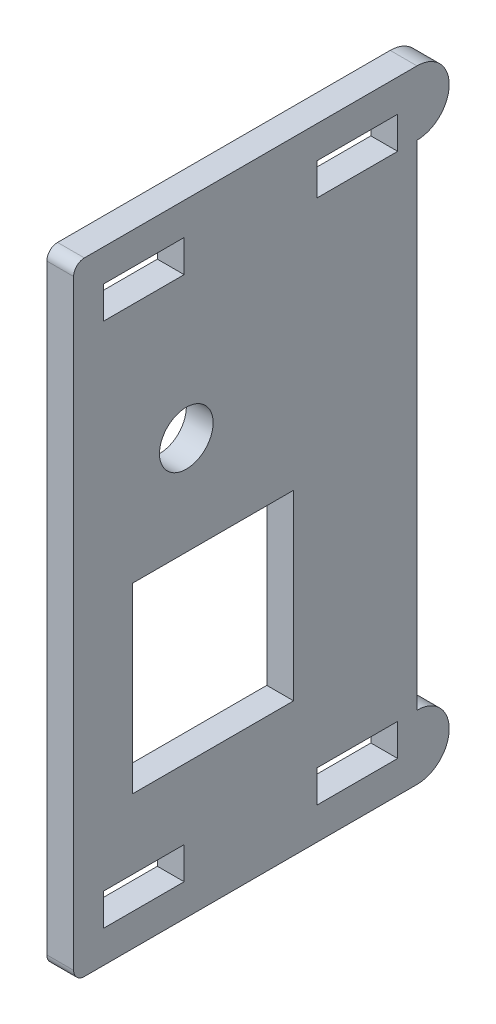
from build123d import *

# Parameters (mm, degrees)
SKETCH_2_W          = 35
SKETCH_2_H          = 58
EXTRUDE_1_DEPTH     = 2.5
SKETCH_4_W          = 7.5
SKETCH_4_H          = 3
CUT_EXTRUDE_1_DEPTH = 3.5
CUT_EXTRUDE_2_DEPTH = 3.5
SKETCH_7_R          = 2.5
SKETCH_7_W          = 15
SKETCH_7_H          = 17
CUT_EXTRUDE_3_DEPTH = 3.5
FILLET_1_R          = 1


with BuildPart() as part:
    # 草图2 → 凸台-拉伸1 (new body)
    with BuildSketch(Plane(origin=(0, 0, 0), x_dir=(0, 0, -1), z_dir=(1, 0, 0))):
        Rectangle(SKETCH_2_W, SKETCH_2_H)
    extrude(amount=EXTRUDE_1_DEPTH)

    # 草图4 → 切除-拉伸1 (cut, through all)
    with BuildSketch(Plane.ZY):
        with Locations((-8.95, 24.5)):
            Rectangle(SKETCH_4_W, SKETCH_4_H)
        with Locations((10.95, 24.5)):
            Rectangle(SKETCH_4_W, SKETCH_4_H)
        with Locations((-8.95, -24.5)):
            Rectangle(SKETCH_4_W, SKETCH_4_H)
        with Locations((10.95, -24.5)):
            Rectangle(SKETCH_4_W, SKETCH_4_H)
    extrude(amount=-CUT_EXTRUDE_1_DEPTH, mode=Mode.SUBTRACT)

    # 草图5 → 切除-拉伸2 (cut, through all)
    with BuildSketch(Plane.ZY):
        with BuildLine():
            Line((-17.5, 29), (-17.5, 26.000000007))
            ThreePointArc((-17.5, 26.000000007), (-16.621320341, 28.121320346), (-14.5, 29))
            Line((-14.5, 29), (-17.5, 29))
        make_face()
        with BuildLine():
            Line((-14.5, 0), (-14.5, 23))
            ThreePointArc((-14.5, 23), (-16.621320346, 23.878679659), (-17.5, 26.000000007))
            Line((-17.5, 26.000000007), (-17.5, 0))
            Line((-17.5, 0), (-14.5, 0))
        make_face()
        with BuildLine():
            Line((-14.5, -23), (-14.5, 0))
            Line((-14.5, 0), (-17.5, 0))
            Line((-17.5, 0), (-17.5, -26))
            ThreePointArc((-17.5, -26), (-16.621320344, -23.878679656), (-14.5, -23))
        make_face()
        with BuildLine():
            ThreePointArc((-14.5, -29), (-16.621320344, -28.121320344), (-17.5, -26))
            Line((-17.5, -26), (-17.5, -29))
            Line((-17.5, -29), (-14.5, -29))
        make_face()
    extrude(amount=-CUT_EXTRUDE_2_DEPTH, mode=Mode.SUBTRACT)

    # 草图7 → 切除-拉伸3 (cut, through all)
    with BuildSketch(Plane.ZY):
        with Locations((7, 9.7)):
            Circle(SKETCH_7_R)
        with Locations((4.5, -8)):
            Rectangle(SKETCH_7_W, SKETCH_7_H)
    extrude(amount=-CUT_EXTRUDE_3_DEPTH, mode=Mode.SUBTRACT)

    # 圆角1
    fillet_1_edges = [part.edges().sort_by_distance(p)[0] for p in [
        (1.25, -29, 17.5),
        (1.25, 29, 17.5),
    ]]
    fillet(fillet_1_edges, radius=FILLET_1_R)


solid = part.part
